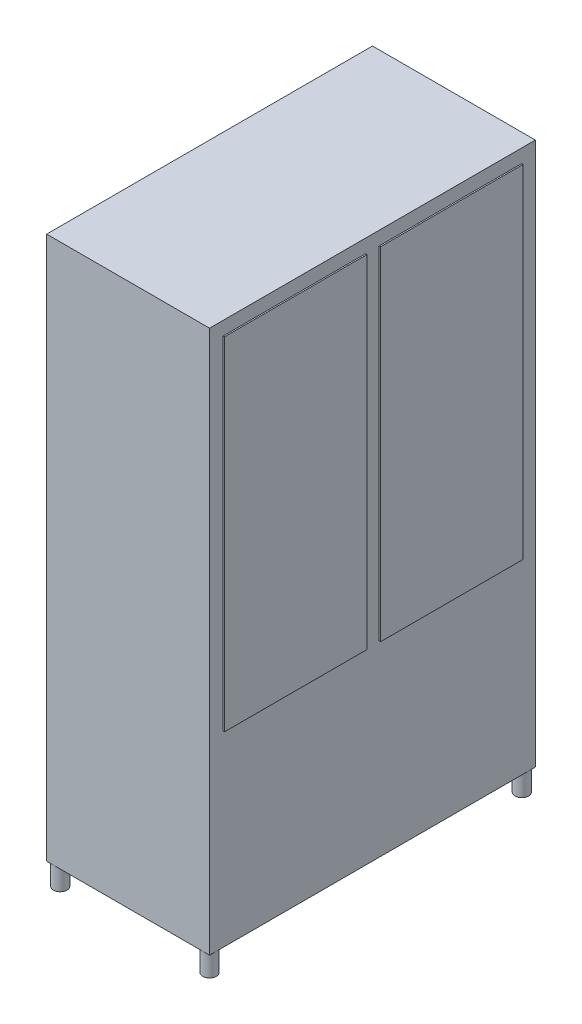
from build123d import *

# Parameters (mm, degrees)
SKETCH_1_W               = 600
SKETCH_1_H               = 1200
EXTRUDE_1_DEPTH          = 2000
SKETCH_2_R               = 25
EXTRUDE_2_DEPTH          = 80
MIRROR_2_COPY_1_SKETCH_R = 25
MIRROR_2_COPY_1_DEPTH    = 80
SKETCH_3_W               = 525
SKETCH_3_H               = 1260
EXTRUDE_3_DEPTH          = 5


with BuildPart() as part:
    # 草图1 → 凸台-拉伸1 (new body)
    with BuildSketch(Plane(origin=(0, 0, 0), x_dir=(1, 0, 0), z_dir=(0, 1, 0))):
        Rectangle(SKETCH_1_W, SKETCH_1_H)
    extrude(amount=EXTRUDE_1_DEPTH)

    # 草图2 → 凸台-拉伸2 (add)
    with BuildSketch(Plane.XZ):
        with Locations((275, 575)):
            Circle(SKETCH_2_R)
    extrude_2 = extrude(amount=EXTRUDE_2_DEPTH)

    # 镜向1: 凸台-拉伸2 across plane
    add(extrude_2.mirror(Plane(origin=(0, 0, 0), x_dir=(0, 0, 1), z_dir=(1, 0, 0))))

    # 镜向2: 凸台-拉伸2 across plane
    add(extrude_2.mirror(Plane.XY))

    # 镜向2 copy 1 sketch → 镜向2 copy 1 (add)
    with BuildSketch(Plane(origin=(0, 0, 0), x_dir=(-1, 0, 0), z_dir=(0, -1, 0))):
        with Locations((275, 575)):
            Circle(MIRROR_2_COPY_1_SKETCH_R)
    extrude(amount=MIRROR_2_COPY_1_DEPTH)

    # 草图3 → 凸台-拉伸3 (add)
    with BuildSketch(Plane(origin=(300, 0, 0), x_dir=(0, 0, -1), z_dir=(1, 0, 0))):
        with Locations((-287.5, 1320)):
            Rectangle(SKETCH_3_W, SKETCH_3_H)
    extrude_3 = extrude(amount=EXTRUDE_3_DEPTH)

    # 镜向3: 凸台-拉伸3 across plane
    add(extrude_3.mirror(Plane.XY))


solid = part.part
